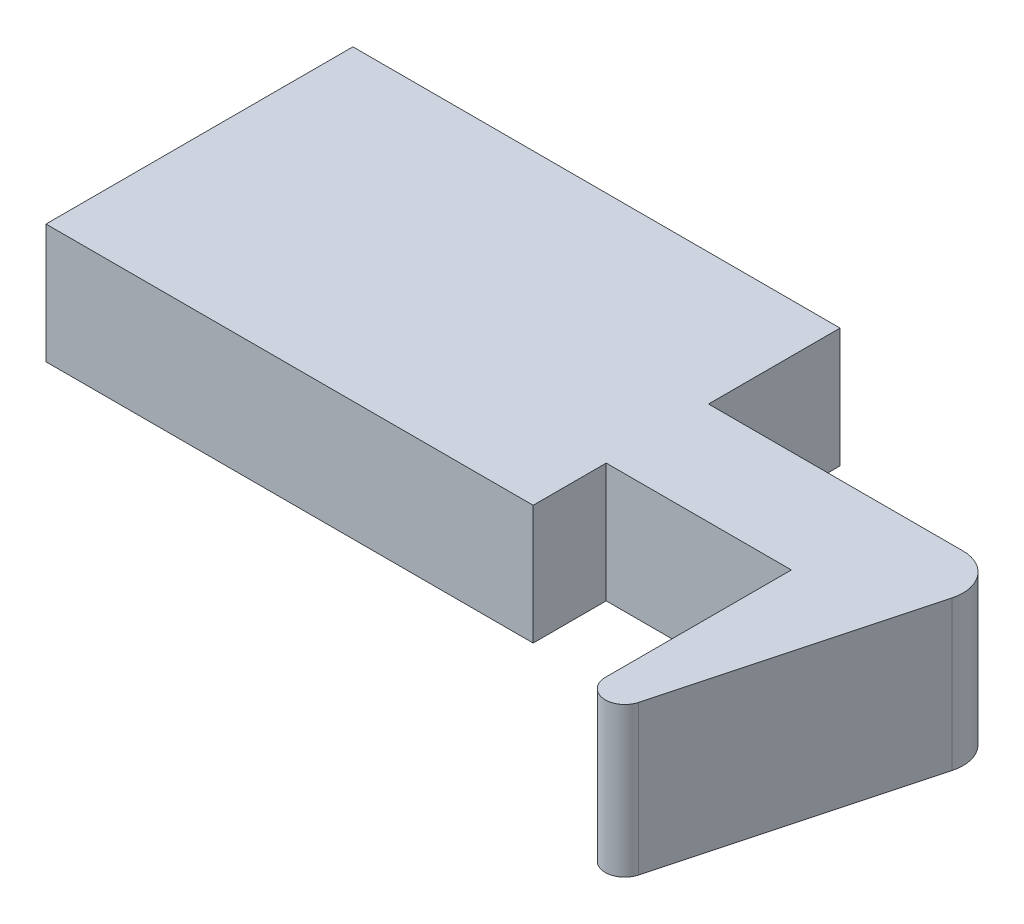
from build123d import *

# Parameters (mm, degrees)
SKETCH2_W           = 9.652
SKETCH2_H           = 5.334
BOSS_EXTRUDE1_DEPTH = 6.223
FILLET1_R           = 1.016
BOSS_EXTRUDE2_DEPTH = 1.5748
FILLET2_R           = 1.905


with BuildPart() as part:
    # Sketch2 → Boss-Extrude1 (new body)
    with BuildSketch(Plane(origin=(0, 0, 0), x_dir=(1, 0, 0), z_dir=(0, 1, 0))):
        Polygon((-9.652, 0), (-9.652, 5.334), (-9.652, 12.192), (-35.052, 12.192), (-35.052, -3.81), (-9.652, -3.81), align=None)
        with Locations((-4.826, 2.667)):
            Rectangle(SKETCH2_W, SKETCH2_H)
        Polygon((0, -17.416581723), (6.096, 5.334), (0, 5.334), (0, 0), align=None)
    extrude(amount=BOSS_EXTRUDE1_DEPTH)

    # Fillet1
    fillet1_edges = [part.edges().sort_by_distance(p)[0] for p in [
        (0, 3.1115, 17.416581723),
    ]]
    fillet(fillet1_edges, radius=FILLET1_R)

    # Sketch3 → Boss-Extrude2 (add)
    with BuildSketch(Plane.XZ):
        with BuildLine():
            Line((0, 9.699295544), (0, 0))
            Line((0, 0), (0, -5.334))
            Line((0, -5.334), (6.096, -5.334))
            Line((6.096, -5.334), (1.99738064, 9.962255694))
            ThreePointArc((1.99738064, 9.962255694), (0.883385389, 10.706603524), (0, 9.699295544))
        make_face()
    extrude(amount=BOSS_EXTRUDE2_DEPTH)

    # Fillet2
    fillet2_edges = [part.edges().sort_by_distance(p)[0] for p in [
        (6.096, 2.3241, -5.334),
    ]]
    fillet(fillet2_edges, radius=FILLET2_R)


solid = part.part
